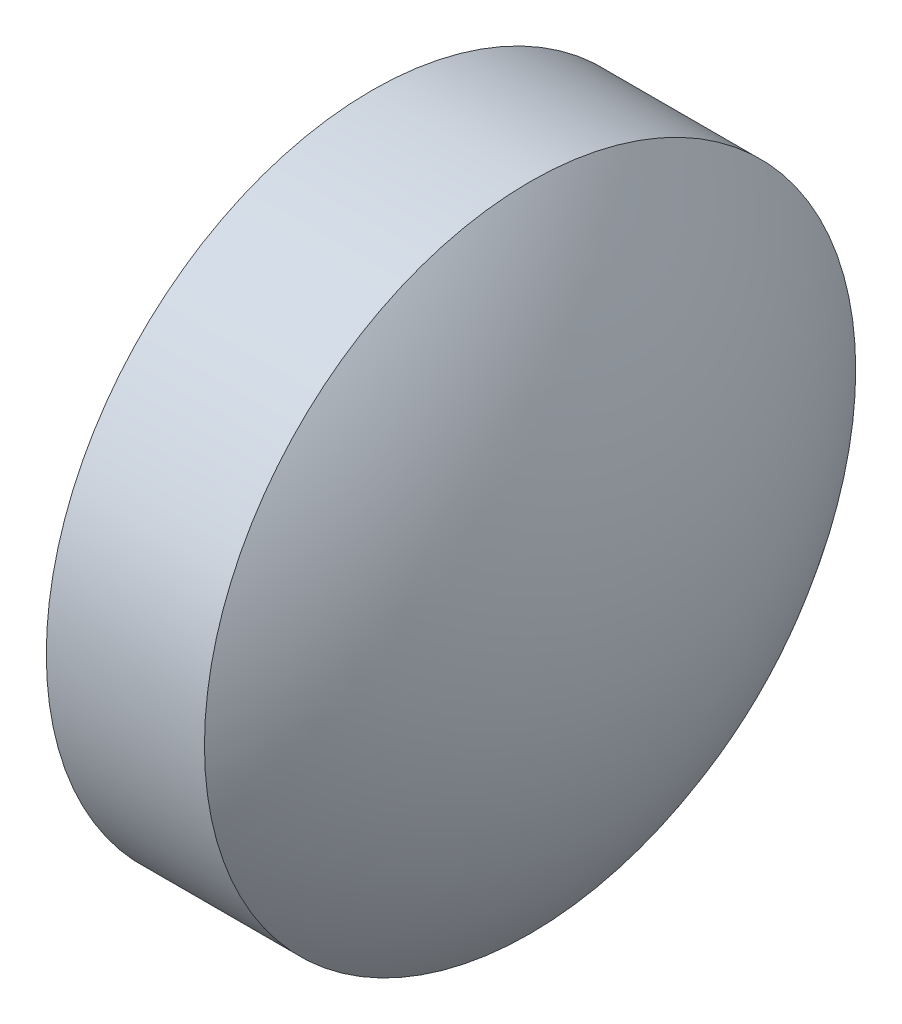
from build123d import *


with BuildPart() as part:
    # 草图2 → 旋转2 (revolve)
    with BuildSketch(Plane.XY):
        with BuildLine():
            Line((486.967485827, 143.668782463), (486.967485827, 146.818782463))
            Line((486.967485827, 146.818782463), (488.497485827, 146.818782463))
            ThreePointArc((488.497485827, 146.818782463), (489.292684961, 145.332167566), (489.567485827, 143.668782463))
            Line((489.567485827, 143.668782463), (486.967485827, 143.668782463))
        make_face()
    revolve(axis=Axis((486.477827843, 143.668782463, 0), (1, 0, 0)))


solid = part.part
